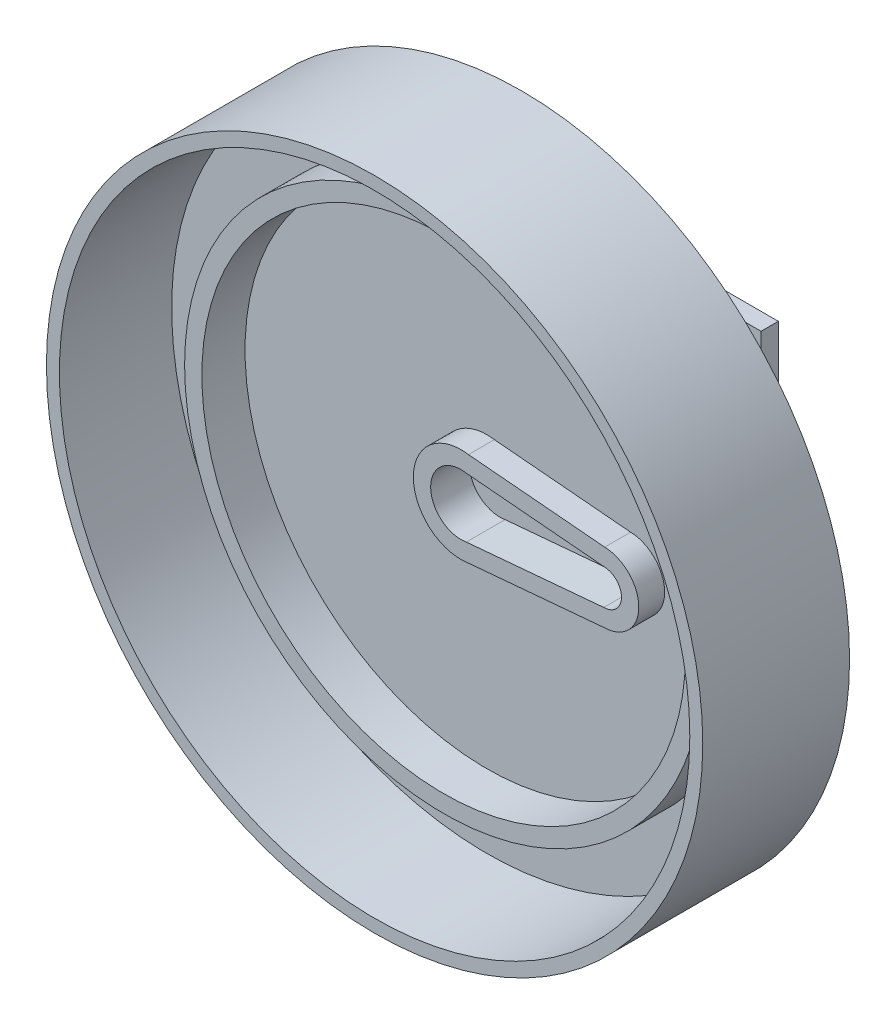
from build123d import *

# Parameters (mm, degrees)
SKETCH2_R             = 30
SKETCH2_R_2           = 28
BOSS_EXTRUDE1_DEPTH   = 5
SKETCH2_R_3           = 38
SKETCH2_R_4           = 36.5
BOSS_EXTRUDE1_2_DEPTH = 5
SKETCH5_R             = 38
BOSS_EXTRUDE2_DEPTH   = 4
BOSS_EXTRUDE3_DEPTH   = 3
CUT_EXTRUDE1_DEPTH    = 1.5
SKETCH10_R            = 38
SKETCH10_R_2          = 36.5
BOSS_EXTRUDE4_DEPTH   = 8
SKETCH11_W            = 20
SKETCH11_H            = 20
BOSS_EXTRUDE5_DEPTH   = 8
SKETCH12_W            = 39.5
SKETCH12_H            = 39.5
BOSS_EXTRUDE6_DEPTH   = 2


with BuildPart() as part:
    # Sketch2 → Boss-Extrude1 (new body)
    with BuildSketch(Plane.XY):
        Circle(SKETCH2_R)
        Circle(SKETCH2_R_2, mode=Mode.SUBTRACT)
    extrude(amount=BOSS_EXTRUDE1_DEPTH)



with BuildPart() as body_2:
    # Sketch2 → Boss-Extrude1 2 (new body)
    with BuildSketch(Plane.XY):
        Circle(SKETCH2_R_3)
        Circle(SKETCH2_R_4, mode=Mode.SUBTRACT)
    extrude(amount=BOSS_EXTRUDE1_2_DEPTH)


with BuildPart() as part_1:
    add(part.part)

    add(body_2.part)  # Boss-Extrude2 merges body 2
    # Sketch5 → Boss-Extrude2 (add)
    with BuildSketch(Plane(origin=(0, 0, 0), x_dir=(-1, 0, 0), z_dir=(0, 0, -1))):
        Circle(SKETCH5_R)
    extrude(amount=BOSS_EXTRUDE2_DEPTH)

    # Sketch6 → Boss-Extrude3 (add)
    with BuildSketch(Plane.XY):
        with BuildLine():
            Line((0.868619612, 5.441102827), (16.642915533, 4.048692183))
            ThreePointArc((16.642915533, 4.048692183), (20.59, 0), (16.642915533, -4.048692183))
            Line((16.642915533, -4.048692183), (0.868619612, -5.441102827))
            ThreePointArc((0.868619612, -5.441102827), (-5.51, 0), (0.868619612, 5.441102827))
        make_face()
        with BuildLine():
            Line((0.614870513, 3.455724852), (16.54, 2.05))
            ThreePointArc((16.54, 2.05), (18.59, 0), (16.54, -2.05))
            Line((16.54, -2.05), (0.614870513, -3.455724852))
            ThreePointArc((0.614870513, -3.455724852), (-3.51, 0), (0.614870513, 3.455724852))
        make_face(mode=Mode.SUBTRACT)
    extrude(amount=BOSS_EXTRUDE3_DEPTH)

    # Sketch9 → Cut-Extrude1 (cut)
    with BuildSketch(Plane.XY):
        with BuildLine():
            Line((0.614870513, 3.455724852), (16.54, 2.05))
            ThreePointArc((16.54, 2.05), (18.59, 0), (16.54, -2.05))
            Line((16.54, -2.05), (0.614870513, -3.455724852))
            ThreePointArc((0.614870513, -3.455724852), (-3.51, 0), (0.614870513, 3.455724852))
        make_face()
    extrude(amount=-CUT_EXTRUDE1_DEPTH, mode=Mode.SUBTRACT)

    # Sketch10 → Boss-Extrude4 (add)
    with BuildSketch(Plane.XY.offset(5)):
        Circle(SKETCH10_R)
        Circle(SKETCH10_R_2, mode=Mode.SUBTRACT)
    extrude(amount=BOSS_EXTRUDE4_DEPTH)

    # Sketch11 → Boss-Extrude5 (add)
    with BuildSketch(Plane(origin=(0, 0, -4), x_dir=(-1, 0, 0), z_dir=(0, 0, -1))):
        Rectangle(SKETCH11_W, SKETCH11_H)
    extrude(amount=BOSS_EXTRUDE5_DEPTH)

    # Sketch12 → Boss-Extrude6 (add)
    with BuildSketch(Plane(origin=(0, 0, -12), x_dir=(-1, 0, 0), z_dir=(0, 0, -1))):
        Rectangle(SKETCH12_W, SKETCH12_H)
    extrude(amount=BOSS_EXTRUDE6_DEPTH)


solid = part_1.part
